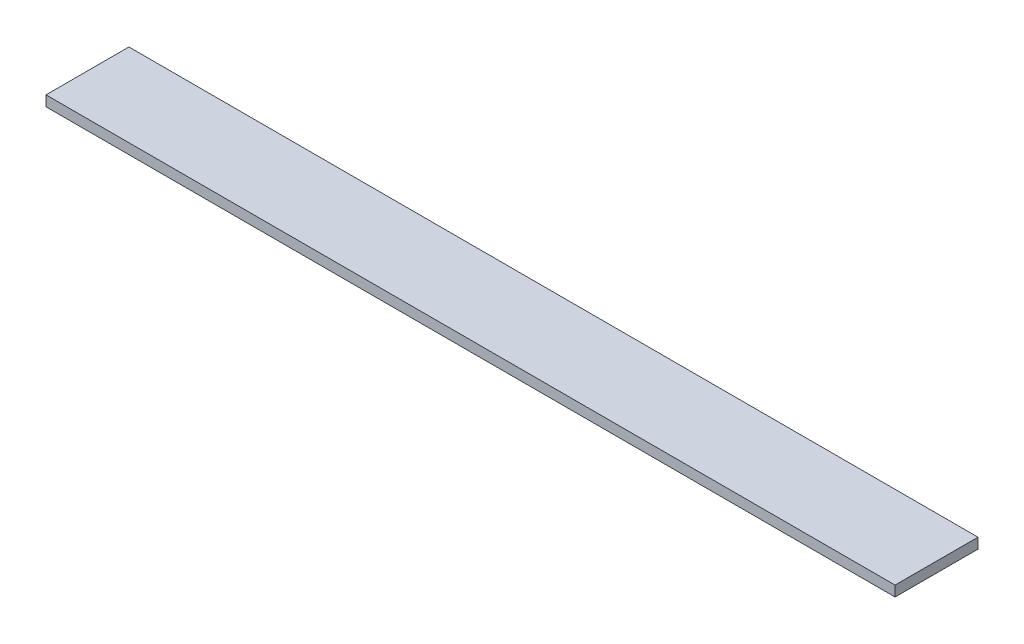
from build123d import *

# Parameters (mm, degrees)
SKETCH1_W           = 260.096
SKETCH1_H           = 25.4
BOSS_EXTRUDE1_DEPTH = 3.175


with BuildPart() as part:
    # Sketch1 → Boss-Extrude1 (new body)
    with BuildSketch(Plane(origin=(0, 0, 0), x_dir=(1, 0, 0), z_dir=(0, 1, 0))):
        with Locations((130.048, 12.7)):
            Rectangle(SKETCH1_W, SKETCH1_H)
    extrude(amount=BOSS_EXTRUDE1_DEPTH)


solid = part.part
